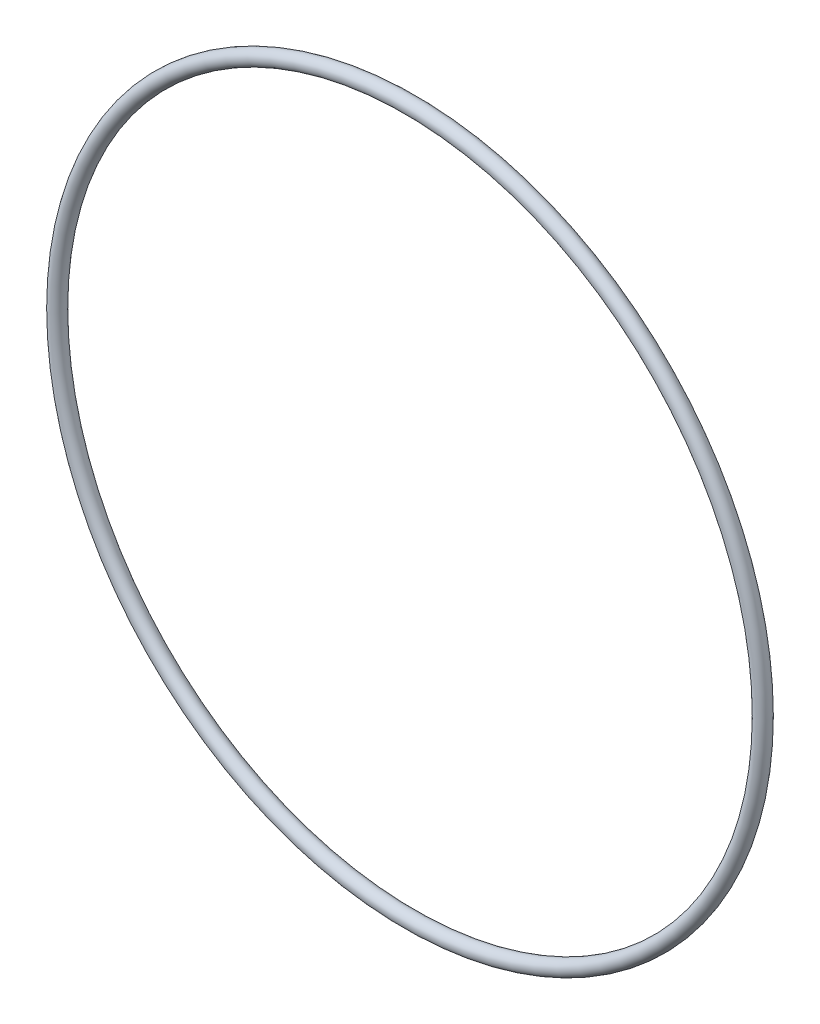
from build123d import *

# Parameters (mm, degrees)
SKETCH1_R = 0.889


with BuildPart() as part:
    # Sketch1 → Revolve1 (revolve)
    with BuildSketch(Plane(origin=(0, 0, 0), x_dir=(0, -1, 0), z_dir=(1, 0, 0))):
        with Locations((42.0243, 0)):
            Circle(SKETCH1_R)
    revolve(axis=Axis((0, 0, 0.889), (0, 0, -1)))


solid = part.part
